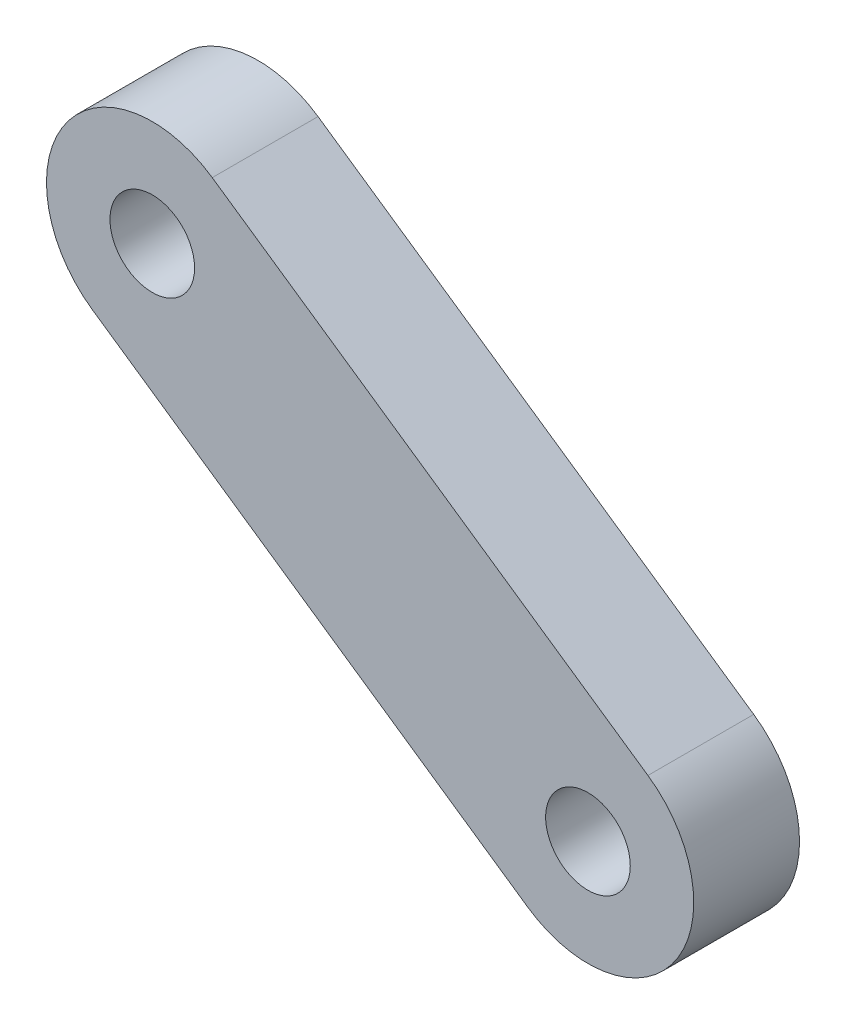
from build123d import *

# Parameters (mm, degrees)
SKETCH1_R           = 2
BOSS_EXTRUDE1_DEPTH = 5


with BuildPart() as part:
    # Sketch1 → Boss-Extrude1 (new body)
    with BuildSketch(Plane(origin=(0, 0, 0), x_dir=(0.999757303, -0.022030336, 0), z_dir=(0, 0, 1))):
        with BuildLine():
            Line((-43.491829272, 87.877240738), (-22.59104637, 74.16019754))
            ThreePointArc((-22.59104637, 74.16019754), (-21.15429843, 67.23663232), (-28.077863649, 65.799884379))
            Line((-28.077863649, 65.799884379), (-48.978646551, 79.516927577))
            ThreePointArc((-48.978646551, 79.516927577), (-50.415394492, 86.440492797), (-43.491829272, 87.877240738))
        make_face()
        with Locations((-25.33445501, 69.980040959)):
            Circle(SKETCH1_R, mode=Mode.SUBTRACT)
        with Locations((-46.235237911, 83.697084158)):
            Circle(SKETCH1_R, mode=Mode.SUBTRACT)
    extrude(amount=BOSS_EXTRUDE1_DEPTH)


solid = part.part
